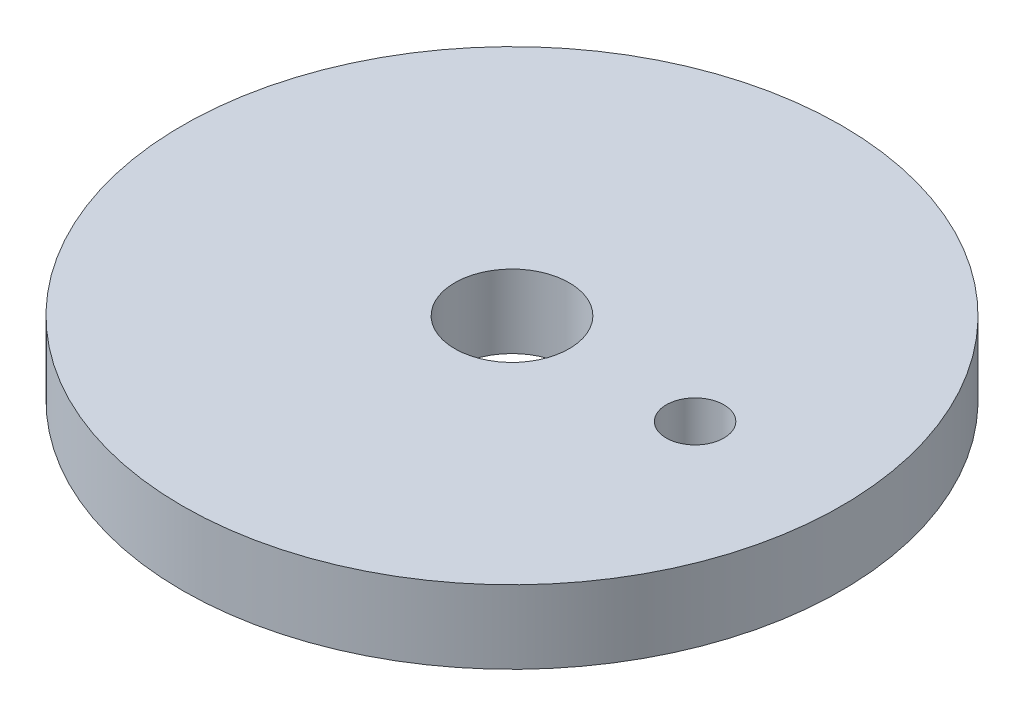
from build123d import *

# Parameters (mm, degrees)
SKETCH1_R           = 22.86
SKETCH1_R_2         = 3.96875
SKETCH1_R_3         = 2
BOSS_EXTRUDE1_DEPTH = 5.08


with BuildPart() as part:
    # Sketch1 → Boss-Extrude1 (new body)
    with BuildSketch(Plane(origin=(0, 0, 0), x_dir=(1, 0, 0), z_dir=(0, 1, 0))):
        Circle(SKETCH1_R)
        Circle(SKETCH1_R_2, mode=Mode.SUBTRACT)
        with Locations((12.7, 0)):
            Circle(SKETCH1_R_3, mode=Mode.SUBTRACT)
    extrude(amount=BOSS_EXTRUDE1_DEPTH)


solid = part.part
